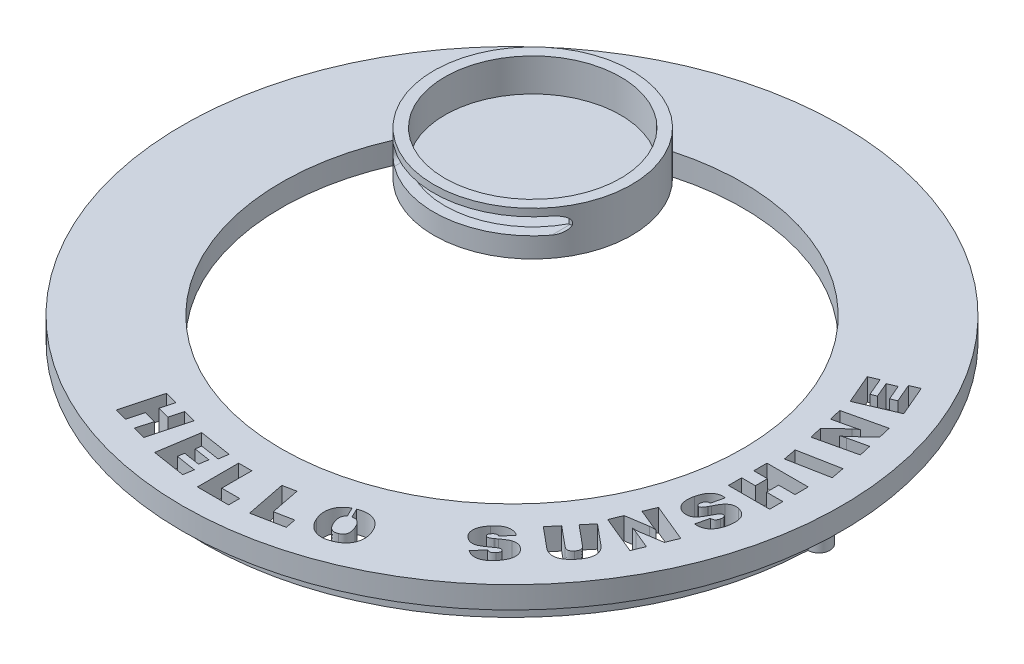
from build123d import *

# Parameters (mm, degrees)
SKETCH1_R            = 30
BOSS_EXTRUDE1_DEPTH  = 2
SKETCH2_R            = 21
CUT_EXTRUDE1_DEPTH   = 2
SKETCH11_R           = 9
BOSS_EXTRUDE3_DEPTH  = 4
SKETCH13_R           = 8
CUT_EXTRUDE10_DEPTH  = 3
CUT_EXTRUDE13_DEPTH  = 10
CUT_EXTRUDE16_DEPTH  = 10
BOSS_EXTRUDE4_DEPTH  = 2
SKETCH20_R           = 28
BOSS_EXTRUDE8_DEPTH  = 2
SKETCH25_R           = 27
CUT_EXTRUDE23_DEPTH  = 2
BOSS_EXTRUDE10_DEPTH = 1
BOSS_EXTRUDE12_DEPTH = 1


with BuildPart() as part:
    # Sketch1 → Boss-Extrude1 (new body)
    with BuildSketch(Plane(origin=(0, 0, 0), x_dir=(1, 0, 0), z_dir=(0, 1, 0))):
        Circle(SKETCH1_R)
    extrude(amount=BOSS_EXTRUDE1_DEPTH)

    # Sketch2 → Cut-Extrude1 (cut)
    with BuildSketch(Plane(origin=(0, 2, 0), x_dir=(1, 0, 0), z_dir=(0, 1, 0))):
        Circle(SKETCH2_R)
    extrude(amount=-CUT_EXTRUDE1_DEPTH, mode=Mode.SUBTRACT)

    # Sketch11 → Boss-Extrude3 (add)
    with BuildSketch(Plane(origin=(0, 0, 0), x_dir=(1, 0, 0), z_dir=(0, 1, 0))):
        with Locations((-11.875702924, 13.763642032)):
            Circle(SKETCH11_R)
    extrude(amount=BOSS_EXTRUDE3_DEPTH)

    # Sketch13 → Cut-Extrude10 (cut)
    with BuildSketch(Plane(origin=(0, 4, 0), x_dir=(1, 0, 0), z_dir=(0, 1, 0))):
        with Locations((-11.875702924, 13.763642032)):
            Circle(SKETCH13_R)
    extrude(amount=-CUT_EXTRUDE10_DEPTH, mode=Mode.SUBTRACT)

    # Sketch16 → Cut-Extrude13 (cut)
    with BuildSketch(Plane.XY):
        with BuildLine():
            Line((-17.291316652, 3.3288405), (-4.708683348, 3.3288405))
            ThreePointArc((-4.708683348, 3.3288405), (-3.958683348, 2.5788405), (-4.708683348, 1.8288405))
            Line((-4.708683348, 1.8288405), (-17.291316652, 1.8288405))
            ThreePointArc((-17.291316652, 1.8288405), (-18.041316652, 2.5788405), (-17.291316652, 3.3288405))
        make_face()
    extrude(amount=-CUT_EXTRUDE13_DEPTH, mode=Mode.SUBTRACT)

    # Sketch18 → Cut-Extrude16 (cut)
    with BuildSketch(Plane(origin=(0, 2, 0), x_dir=(1, 0, 0), z_dir=(0, 1, 0))):
        Polygon((25.568850468, 10.095220619), (22.153206132, 8.631695196), (20.985843532, 11.355040141), (21.803673866, 11.705324089), (22.496724939, 10.088455479), (22.977801606, 10.294416427), (22.392241101, 11.661726517), (23.161963768, 11.991715043), (23.747524274, 10.624404953), (24.276708608, 10.851413005), (23.555093607, 12.53518134), (24.372923941, 12.885465288), align=None)
        with BuildLine():
            Line((26.843323164, 4.870106811), (23.187140494, 4.025967597))
            Line((23.187140494, 4.025967597), (22.931568515, 5.132443931))
            Line((22.931568515, 5.132443931), (24.396597303, 6.544854958))
            add(Edge.make_bspline(
                [(24.396597303, 6.544854958), (24.407714969, 6.556050004), (24.431612554, 6.580113917), (24.473622755, 6.615070259), (24.521946307, 6.653336523), (24.57830382, 6.693091142), (24.64107318, 6.735896512), (24.711215061, 6.780517229), (24.786764614, 6.82913531), (24.840229914, 6.860740529), (24.8679021, 6.877098531)],
                knots=[0, 0, 0, 0, 4.7308e-05, 0.00010169, 0.000163793, 0.000232213, 0.000308519, 0.000391712, 0.00048159, 0.000578017, 0.000578017, 0.000578017, 0.000578017], degree=3))
            add(Edge.make_bspline(
                [(24.8679021, 6.877098531), (24.835146764, 6.865131705), (24.766293518, 6.839976875), (24.676460208, 6.810833605), (24.596901056, 6.788515417), (24.529767515, 6.770398385), (24.456418745, 6.751549036), (24.405143101, 6.739680824), (24.378556928, 6.733527214)],
                knots=[0, 0, 0, 0, 0.000104616, 0.000219908, 0.000283201, 0.000352491, 0.000428515, 0.000510379, 0.000510379, 0.000510379, 0.000510379], degree=3))
            Line((24.378556928, 6.733527214), (22.653446067, 6.335135599))
            Line((22.653446067, 6.335135599), (22.398625769, 7.441611933))
            Line((22.398625769, 7.441611933), (26.05480844, 8.285751147))
            Line((26.05480844, 8.285751147), (26.309628737, 7.179274813))
            Line((26.309628737, 7.179274813), (24.85813023, 5.769870515))
            add(Edge.make_bspline(
                [(24.85813023, 5.769870515), (24.846467171, 5.758720325), (24.821049453, 5.734420319), (24.777677595, 5.698301351), (24.726881479, 5.658805259), (24.646353308, 5.601619029), (24.53214561, 5.52460902), (24.435186151, 5.465293087), (24.383818704, 5.43386853)],
                knots=[0, 0, 0, 0, 4.8395e-05, 0.000105468, 0.000169219, 0.000241396, 0.000401718, 0.000582349, 0.000582349, 0.000582349, 0.000582349], degree=3))
            add(Edge.make_bspline(
                [(24.383818704, 5.43386853), (24.41551991, 5.446706641), (24.480052534, 5.472840566), (24.56510704, 5.50154122), (24.641344107, 5.522748364), (24.70951662, 5.541931906), (24.788854338, 5.561170533), (24.845339279, 5.574238983), (24.875418923, 5.581198259)],
                knots=[0, 0, 0, 0, 0.000102596, 0.000208849, 0.000269045, 0.000339982, 0.000421293, 0.000513917, 0.000513917, 0.000513917, 0.000513917], degree=3))
            Line((24.875418923, 5.581198259), (26.587751185, 5.976583145))
            Line((26.587751185, 5.976583145), (26.843323164, 4.870106811))
        make_face()
        Polygon((27.358585925, 1.795526283), (23.702403255, 1.098716798), (23.473140156, 2.301408465), (27.129322826, 2.99821795), align=None)
        Polygon((26.989940597, -3.536921403), (23.237542594, -3.536921403), (23.237542594, -2.334229735), (24.488341928, -2.334229735), (24.488341928, -1.227753401), (23.237542594, -1.227753401), (23.237542594, -0.025061733), (26.989940597, -0.025061733), (26.989940597, -1.227753401), (25.498602929, -1.227753401), (25.498602929, -2.334229735), (26.989940597, -2.334229735), align=None)
        with BuildLine():
            Line((24.740732099, -8.107504989), (25.009082677, -6.952920988))
            add(Edge.make_bspline(
                [(25.009082677, -6.952920988), (25.042983102, -6.952410304), (25.106995881, -6.951445999), (25.197174908, -6.934922553), (25.275425094, -6.906585767), (25.343033021, -6.864837367), (25.399579396, -6.806686167), (25.44565617, -6.732231968), (25.48431763, -6.641938031), (25.501855246, -6.575122385), (25.511206449, -6.539495727)],
                knots=[0, 0, 0, 0, 0.000101577, 0.000191804, 0.000273624, 0.000349956, 0.000428091, 0.000514626, 0.000611254, 0.000721631, 0.000721631, 0.000721631, 0.000721631], degree=3))
            add(Edge.make_bspline(
                [(25.511206449, -6.539495727), (25.517494981, -6.509038793), (25.529425415, -6.451256722), (25.534502497, -6.366879102), (25.530481015, -6.290419033), (25.513130069, -6.222524542), (25.48552969, -6.164779367), (25.448050324, -6.117088013), (25.397876918, -6.083993633), (25.35998612, -6.072053066), (25.340574568, -6.065935883)],
                knots=[0, 0, 0, 0, 9.3184e-05, 0.000176787, 0.000252889, 0.000321986, 0.000385525, 0.000443755, 0.000501712, 0.000562594, 0.000562594, 0.000562594, 0.000562594], degree=3))
            add(Edge.make_bspline(
                [(25.340574568, -6.065935883), (25.323785901, -6.063706897), (25.289648852, -6.059174614), (25.236199895, -6.071040728), (25.183817738, -6.099226792), (25.129695476, -6.14054443), (25.076327822, -6.198273529), (25.020280224, -6.269318388), (24.964518814, -6.356078614), (24.929257153, -6.420003307), (24.910612297, -6.453803946)],
                knots=[0, 0, 0, 0, 5.0503e-05, 0.000102689, 0.000160846, 0.000227898, 0.000306048, 0.000395973, 0.000499176, 0.000614974, 0.000614974, 0.000614974, 0.000614974], degree=3))
            add(Edge.make_bspline(
                [(24.910612297, -6.453803946), (24.903324859, -6.467322912), (24.889708141, -6.492583358), (24.870871325, -6.528272933), (24.854384665, -6.55873452), (24.844450376, -6.577573563), (24.839954162, -6.586100029)],
                knots=[0, 0, 0, 0, 4.6074e-05, 8.609e-05, 0.000121065, 0.000149983, 0.000149983, 0.000149983, 0.000149983], degree=3))
            add(Edge.make_bspline(
                [(24.839954162, -6.586100029), (24.808570707, -6.646333619), (24.749106485, -6.760462022), (24.66183596, -6.920951818), (24.5818083, -7.061549959), (24.507978454, -7.182720943), (24.439779639, -7.285421313), (24.378751495, -7.372537435), (24.321755401, -7.443206036), (24.283219658, -7.482844422), (24.26566889, -7.500897379)],
                knots=[0, 0, 0, 0, 0.000203754, 0.000386066, 0.000548015, 0.000689051, 0.000811638, 0.000917806, 0.001008086, 0.001083592, 0.001083592, 0.001083592, 0.001083592], degree=3))
            add(Edge.make_bspline(
                [(24.26566889, -7.500897379), (24.232765583, -7.528858882), (24.168511923, -7.583462173), (24.062006481, -7.649042022), (23.952496461, -7.70171763), (23.837565923, -7.737982167), (23.718796326, -7.759210642), (23.595879978, -7.764632649), (23.468865551, -7.75699181), (23.384294171, -7.739729048), (23.341099671, -7.730912161)],
                knots=[0, 0, 0, 0, 0.000129368, 0.00025263, 0.000374015, 0.000493115, 0.000612992, 0.000734913, 0.000861466, 0.000993578, 0.000993578, 0.000993578, 0.000993578], degree=3))
            add(Edge.make_bspline(
                [(23.341099671, -7.730912161), (23.298222352, -7.719525858), (23.214346514, -7.69725218), (23.09555003, -7.649366947), (22.986819677, -7.591006115), (22.888614042, -7.520729214), (22.800003614, -7.440178234), (22.722170119, -7.347356645), (22.654294844, -7.243929838), (22.597282286, -7.129751943), (22.550902009, -7.006855122), (22.516186536, -6.875891204), (22.493999951, -6.737638872), (22.48295308, -6.592082409), (22.483006155, -6.439287539), (22.495505725, -6.279311519), (22.519622615, -6.112117912), (22.543885251, -5.999158011), (22.556343357, -5.941156623)],
                knots=[0, 0, 0, 0, 0.000132988, 0.000260149, 0.000383251, 0.000502352, 0.000621531, 0.000741548, 0.000864762, 0.000991832, 0.001123623, 0.001258183, 0.001397577, 0.001543089, 0.00169568, 0.00185549, 0.002024088, 0.002202021, 0.002202021, 0.002202021, 0.002202021], degree=3))
            add(Edge.make_bspline(
                [(22.556343357, -5.941156623), (22.570403042, -5.884579159), (22.597823574, -5.774236414), (22.649941902, -5.616391088), (22.708790977, -5.469826349), (22.773349099, -5.334229109), (22.847052917, -5.210791184), (22.927112103, -5.098526036), (23.01484014, -4.997949882), (23.108925004, -4.908677202), (23.209886371, -4.831640654), (23.317100118, -4.767437191), (23.429798988, -4.716051116), (23.547924427, -4.677086523), (23.671948709, -4.652956964), (23.801036453, -4.639773192), (23.935796572, -4.640837927), (24.02669567, -4.650720027), (24.073238223, -4.655779903)],
                knots=[0, 0, 0, 0, 0.000174847, 0.000341002, 0.000498174, 0.000648452, 0.00079103, 0.000928918, 0.001061575, 0.001190788, 0.001317374, 0.001441775, 0.001564888, 0.001688258, 0.001814005, 0.001943176, 0.002076977, 0.002217373, 0.002217373, 0.002217373, 0.002217373], degree=3))
            Line((24.073238223, -4.655779903), (23.815411197, -5.762256237))
            add(Edge.make_bspline(
                [(23.815411197, -5.762256237), (23.787579748, -5.761334855), (23.734067969, -5.759563306), (23.65679324, -5.771810065), (23.588276273, -5.799925461), (23.527361412, -5.840073952), (23.476150891, -5.895853455), (23.43233752, -5.964411052), (23.397120302, -6.047661498), (23.381127948, -6.10878088), (23.372670327, -6.141104112)],
                knots=[0, 0, 0, 0, 8.3437e-05, 0.000160425, 0.00023259, 0.000304099, 0.000377479, 0.000457962, 0.000547187, 0.000647342, 0.000647342, 0.000647342, 0.000647342], degree=3))
            add(Edge.make_bspline(
                [(23.372670327, -6.141104112), (23.366845415, -6.169817979), (23.355922494, -6.223662443), (23.34893385, -6.300679038), (23.353880658, -6.368285969), (23.368884615, -6.4266291), (23.396382879, -6.475309261), (23.434148654, -6.51505609), (23.483912079, -6.543906161), (23.52145242, -6.554837208), (23.54104716, -6.560542831)],
                knots=[0, 0, 0, 0, 8.7873e-05, 0.00016478, 0.000231137, 0.000290406, 0.000343923, 0.000397086, 0.000453034, 0.000514124, 0.000514124, 0.000514124, 0.000514124], degree=3))
            add(Edge.make_bspline(
                [(23.54104716, -6.560542831), (23.556618, -6.562570616), (23.588722263, -6.566751542), (23.638721688, -6.55269209), (23.688481463, -6.523960463), (23.739668944, -6.480891704), (23.791832368, -6.422937387), (23.846187953, -6.350795668), (23.901452992, -6.263296738), (23.936574122, -6.198705453), (23.955224104, -6.164406263)],
                knots=[0, 0, 0, 0, 4.6701e-05, 9.6289e-05, 0.000152142, 0.000218358, 0.000296026, 0.000385627, 0.000489054, 0.000606162, 0.000606162, 0.000606162, 0.000606162], degree=3))
            add(Edge.make_bspline(
                [(23.955224104, -6.164406263), (23.961543262, -6.153412289), (23.972556232, -6.134252097), (23.983066771, -6.11481217), (23.987546442, -6.106526727)],
                knots=[0, 0, 0, 0, 3.804e-05, 6.6296e-05, 6.6296e-05, 6.6296e-05, 6.6296e-05], degree=3))
            add(Edge.make_bspline(
                [(23.987546442, -6.106526727), (23.993814682, -6.094251395), (24.007625118, -6.067205897), (24.030404663, -6.022344631), (24.057393565, -5.969315703), (24.076527291, -5.930899627), (24.086768505, -5.910337649)],
                knots=[0, 0, 0, 0, 4.1349e-05, 9.1103e-05, 0.00015094, 0.000219854, 0.000219854, 0.000219854, 0.000219854], degree=3))
            add(Edge.make_bspline(
                [(24.086768505, -5.910337649), (24.111398285, -5.863137917), (24.1584904, -5.772892079), (24.228747305, -5.645030018), (24.293528956, -5.529586022), (24.355759057, -5.42848329), (24.413808126, -5.340807508), (24.46716334, -5.266151829), (24.515662123, -5.203750367), (24.549989315, -5.169645178), (24.565590125, -5.154145262)],
                knots=[0, 0, 0, 0, 0.000159713, 0.00030537, 0.000437671, 0.000556793, 0.000661449, 0.000753025, 0.000832149, 0.000898066, 0.000898066, 0.000898066, 0.000898066], degree=3))
            add(Edge.make_bspline(
                [(24.565590125, -5.154145262), (24.600685988, -5.12217038), (24.668594853, -5.060300467), (24.779443481, -4.985048255), (24.89106026, -4.925929059), (25.005829493, -4.885297993), (25.124580198, -4.861994213), (25.248341157, -4.853699491), (25.37821225, -4.862127413), (25.46501391, -4.879735846), (25.509703084, -4.888801413)],
                knots=[0, 0, 0, 0, 0.000142275, 0.000275295, 0.0004007, 0.000520283, 0.000639101, 0.000762654, 0.000891458, 0.001028142, 0.001028142, 0.001028142, 0.001028142], degree=3))
            add(Edge.make_bspline(
                [(25.509703084, -4.888801413), (25.557618258, -4.901075173), (25.65091304, -4.924973191), (25.782627028, -4.976815779), (25.902660256, -5.039149537), (26.011732938, -5.112421892), (26.107855133, -5.198132336), (26.194290941, -5.293351939), (26.267086829, -5.400985237), (26.328124431, -5.518890628), (26.376991153, -5.646781174), (26.413690715, -5.783804583), (26.437595936, -5.929832709), (26.448613535, -6.084786949), (26.446533067, -6.248612703), (26.432777151, -6.421368431), (26.406497857, -6.602938568), (26.379675083, -6.725810971), (26.365869215, -6.789054248)],
                knots=[0, 0, 0, 0, 0.000148272, 0.000288698, 0.00042352, 0.000553406, 0.00068175, 0.000808971, 0.000938237, 0.001070364, 0.00120647, 0.001348148, 0.001495203, 0.00164971, 0.001813584, 0.00198625, 0.002169306, 0.002363457, 0.002363457, 0.002363457, 0.002363457], degree=3))
            add(Edge.make_bspline(
                [(26.365869215, -6.789054248), (26.351396678, -6.847165175), (26.323189582, -6.96042385), (26.268345281, -7.122396448), (26.207110662, -7.273413858), (26.137302629, -7.412863965), (26.059079134, -7.540571623), (25.972191799, -7.65630568), (25.877385001, -7.760361139), (25.775031224, -7.852494852), (25.665551612, -7.931624633), (25.550502584, -7.998418126), (25.428896985, -8.050305856), (25.302125108, -8.090094316), (25.169047207, -8.114250941), (25.030918642, -8.126358344), (24.887102216, -8.125087919), (24.790268644, -8.113455641), (24.740732099, -8.107504989)],
                knots=[0, 0, 0, 0, 0.000179591, 0.000350024, 0.000512505, 0.000668149, 0.00081731, 0.000961182, 0.001101648, 0.001238982, 0.001373552, 0.001506226, 0.001637202, 0.001769395, 0.001903997, 0.00204208, 0.002184907, 0.002334498, 0.002334498, 0.002334498, 0.002334498], degree=3))
        make_face()
        with BuildLine():
            Line((23.893372821, -13.155473877), (20.429620818, -11.720512381))
            Line((20.429620818, -11.720512381), (20.867851595, -10.662143713))
            Line((20.867851595, -10.662143713), (22.884615185, -10.350195562))
            add(Edge.make_bspline(
                [(22.884615185, -10.350195562), (22.900372968, -10.347489774), (22.934000838, -10.341715493), (22.988512616, -10.336843184), (23.050197814, -10.333929447), (23.119400547, -10.333258522), (23.195574441, -10.335138299), (23.278823382, -10.337689872), (23.368483741, -10.344242769), (23.430590808, -10.349159992), (23.462658868, -10.351698927)],
                knots=[0, 0, 0, 0, 4.7949e-05, 0.000102325, 0.000164036, 0.000233195, 0.000309882, 0.000392621, 0.000483023, 0.000579532, 0.000579532, 0.000579532, 0.000579532], degree=3))
            add(Edge.make_bspline(
                [(23.462658868, -10.351698927), (23.428781706, -10.342359747), (23.35792849, -10.322827093), (23.267697526, -10.294640076), (23.189790235, -10.266958531), (23.124754057, -10.242086567), (23.054075146, -10.214314288), (23.005361609, -10.194406237), (22.980078836, -10.184073776)],
                knots=[0, 0, 0, 0, 0.000105421, 0.000220484, 0.000283487, 0.00035343, 0.000429365, 0.000511301, 0.000511301, 0.000511301, 0.000511301], degree=3))
            Line((22.980078836, -10.184073776), (21.345921532, -9.507559712))
            Line((21.345921532, -9.507559712), (21.784903991, -8.449191045))
            Line((21.784903991, -8.449191045), (25.248655994, -9.884152541))
            Line((25.248655994, -9.884152541), (24.809673536, -10.942521209))
            Line((24.809673536, -10.942521209), (22.805688544, -11.259731136))
            add(Edge.make_bspline(
                [(22.805688544, -11.259731136), (22.789420057, -11.26212828), (22.75447682, -11.267277129), (22.698038418, -11.272380444), (22.633837012, -11.275256356), (22.534807482, -11.276039441), (22.397120348, -11.271785227), (22.283746324, -11.26389635), (22.22388645, -11.259731136)],
                knots=[0, 0, 0, 0, 4.9325e-05, 0.000105947, 0.00016991, 0.000242076, 0.000402999, 0.000583005, 0.000583005, 0.000583005, 0.000583005], degree=3))
            add(Edge.make_bspline(
                [(22.22388645, -11.259731136), (22.257071526, -11.267588536), (22.324739198, -11.283610555), (22.409985424, -11.310811788), (22.484357864, -11.336754234), (22.550804508, -11.360561726), (22.626347419, -11.39113137), (22.680155976, -11.412830212), (22.708721529, -11.424349558)],
                knots=[0, 0, 0, 0, 0.000102276, 0.00020855, 0.000268218, 0.000338604, 0.000420261, 0.000512666, 0.000512666, 0.000512666, 0.000512666], degree=3))
            Line((22.708721529, -11.424349558), (24.331603598, -12.09710521))
            Line((24.331603598, -12.09710521), (23.893372821, -13.155473877))
        make_face()
        with BuildLine():
            Line((18.06738426, -15.216797358), (18.825831693, -14.30275169))
            Line((18.825831693, -14.30275169), (20.587023304, -15.764022067))
            add(Edge.make_bspline(
                [(20.587023304, -15.764022067), (20.606861887, -15.780079938), (20.645183087, -15.811098127), (20.70388021, -15.851501655), (20.760383975, -15.885871435), (20.815434693, -15.913086925), (20.868640594, -15.933856133), (20.920510951, -15.946593101), (20.970118615, -15.953705785), (21.018574832, -15.954150893), (21.065932242, -15.945757836), (21.113696335, -15.93261363), (21.161536451, -15.910879933), (21.209243623, -15.882059844), (21.257708398, -15.847342151), (21.306041473, -15.80539649), (21.354800929, -15.756680831), (21.385808311, -15.720399164), (21.401846909, -15.701632436)],
                knots=[0, 0, 0, 0, 7.6543e-05, 0.000147853, 0.000213599, 0.000274781, 0.000331879, 0.000384567, 0.000434637, 0.000481993, 0.0005292, 0.000578451, 0.000630273, 0.000686222, 0.000745466, 0.000808898, 0.000877996, 0.000952031, 0.000952031, 0.000952031, 0.000952031], degree=3))
            add(Edge.make_bspline(
                [(21.401846909, -15.701632436), (21.416859449, -15.682762164), (21.44589509, -15.646265312), (21.484085881, -15.590797774), (21.516384486, -15.537120161), (21.541252283, -15.484465902), (21.55959987, -15.433138869), (21.571214317, -15.383187445), (21.575637284, -15.334657057), (21.574434889, -15.287352072), (21.565829153, -15.240221982), (21.549806455, -15.193068488), (21.526703004, -15.144973734), (21.496588845, -15.096463934), (21.459310841, -15.047188309), (21.414621246, -14.997879227), (21.363433851, -14.947122809), (21.325409796, -14.914863666), (21.305631576, -14.898084066)],
                knots=[0, 0, 0, 0, 7.2322e-05, 0.000139877, 0.000201885, 0.000260057, 0.000314261, 0.000365138, 0.000413456, 0.000460085, 0.000506677, 0.000556595, 0.000609046, 0.000666415, 0.000727602, 0.000794146, 0.000865904, 0.000943687, 0.000943687, 0.000943687, 0.000943687], degree=3))
            Line((21.305631576, -14.898084066), (19.544439965, -13.436813689))
            Line((19.544439965, -13.436813689), (20.30363908, -12.522768022))
            Line((20.30363908, -12.522768022), (22.136240509, -14.043421299))
            add(Edge.make_bspline(
                [(22.136240509, -14.043421299), (22.178815265, -14.08048283), (22.261803437, -14.152724432), (22.370956527, -14.271234626), (22.463509169, -14.393526431), (22.539538988, -14.51985077), (22.598870478, -14.650617816), (22.640495665, -14.786023479), (22.664583684, -14.92571334), (22.671880443, -15.069004195), (22.662916203, -15.215575225), (22.635769681, -15.364605523), (22.592753245, -15.515908658), (22.532485894, -15.669479873), (22.455657947, -15.825198828), (22.360434967, -15.98244684), (22.250187748, -16.142976578), (22.16651258, -16.247134319), (22.12346191, -16.300723223)],
                knots=[0, 0, 0, 0, 0.000169237, 0.000329883, 0.000482324, 0.00062864, 0.000771287, 0.000912047, 0.001052432, 0.00119545, 0.001341555, 0.001491955, 0.001649001, 0.00181274, 0.001986203, 0.002169259, 0.002363795, 0.002569949, 0.002569949, 0.002569949, 0.002569949], degree=3))
            add(Edge.make_bspline(
                [(22.12346191, -16.300723223), (22.078484445, -16.353154013), (21.991044576, -16.455083754), (21.853278942, -16.594314318), (21.714938388, -16.716765373), (21.575649347, -16.821940888), (21.435122123, -16.909903686), (21.293800232, -16.981028594), (21.151228914, -17.034989243), (21.008425105, -17.072478108), (20.865241364, -17.091008485), (20.722913743, -17.093885085), (20.581710483, -17.077844671), (20.442002458, -17.043782694), (20.303094196, -16.99454401), (20.166424435, -16.925365741), (20.030247528, -16.84037588), (19.944211209, -16.772395041), (19.899985689, -16.737450635)],
                knots=[0, 0, 0, 0, 0.000207188, 0.00040279, 0.000587067, 0.000761006, 0.000925781, 0.001083777, 0.001234835, 0.001382328, 0.001525634, 0.001666968, 0.001808416, 0.001950625, 0.002097563, 0.002249509, 0.002409264, 0.002578245, 0.002578245, 0.002578245, 0.002578245], degree=3))
            Line((19.899985689, -16.737450635), (18.06738426, -15.216797358))
        make_face()
        with BuildLine():
            Line((16.584587875, -20.487263593), (17.34378699, -19.573217926))
            add(Edge.make_bspline(
                [(17.34378699, -19.573217926), (17.372991461, -19.586925876), (17.428537576, -19.612998026), (17.513642792, -19.635874936), (17.593959934, -19.64383532), (17.670930519, -19.633813611), (17.744914187, -19.605199335), (17.818293439, -19.559118995), (17.892093185, -19.495135835), (17.937519596, -19.443053435), (17.961669835, -19.415364644)],
                knots=[0, 0, 0, 0, 9.6628e-05, 0.000183785, 0.000263001, 0.000337311, 0.000414379, 0.00049908, 0.000596102, 0.000706231, 0.000706231, 0.000706231, 0.000706231], degree=3))
            add(Edge.make_bspline(
                [(17.961669835, -19.415364644), (17.981036392, -19.390978892), (18.017811873, -19.344672379), (18.061270665, -19.272365049), (18.090498608, -19.202156435), (18.107325295, -19.135172939), (18.109117827, -19.071771149), (18.097631483, -19.013405148), (18.069468564, -18.961726528), (18.041403474, -18.935107781), (18.027066194, -18.921509378)],
                knots=[0, 0, 0, 0, 9.336e-05, 0.000177283, 0.000252105, 0.000320841, 0.000383249, 0.000440894, 0.000497405, 0.000556425, 0.000556425, 0.000556425, 0.000556425], degree=3))
            add(Edge.make_bspline(
                [(18.027066194, -18.921509378), (18.013450173, -18.912397861), (17.985760149, -18.893868356), (17.934031502, -18.881157764), (17.875863172, -18.883387005), (17.810265371, -18.896517832), (17.738139443, -18.924273387), (17.65782279, -18.963008026), (17.57047077, -19.015147359), (17.511161201, -19.056187271), (17.479841485, -19.077859295)],
                knots=[0, 0, 0, 0, 4.8859e-05, 9.9362e-05, 0.000156495, 0.00022239, 0.000299198, 0.000387619, 0.000489721, 0.000603969, 0.000603969, 0.000603969, 0.000603969], degree=3))
            add(Edge.make_bspline(
                [(17.479841485, -19.077859295), (17.46758014, -19.086901614), (17.444347465, -19.104034909), (17.411635274, -19.127646804), (17.383774872, -19.148222908), (17.366606792, -19.160319854), (17.358820636, -19.165806123)],
                knots=[0, 0, 0, 0, 4.5705e-05, 8.66e-05, 0.00012103, 0.000149604, 0.000149604, 0.000149604, 0.000149604], degree=3))
            add(Edge.make_bspline(
                [(17.358820636, -19.165806123), (17.303787827, -19.205270379), (17.199445581, -19.280094637), (17.050063692, -19.384293003), (16.915456305, -19.472860083), (16.79624893, -19.548104516), (16.690342038, -19.609883569), (16.596131676, -19.658651245), (16.514236302, -19.697652734), (16.461735244, -19.714974799), (16.438009828, -19.722802702)],
                knots=[0, 0, 0, 0, 0.000203162, 0.000385194, 0.000546351, 0.000686505, 0.000808085, 0.000913989, 0.001004815, 0.001079701, 0.001079701, 0.001079701, 0.001079701], degree=3))
            add(Edge.make_bspline(
                [(16.438009828, -19.722802702), (16.396087457, -19.732505878), (16.313910861, -19.751526127), (16.189454849, -19.76373992), (16.067706788, -19.75997832), (15.948773418, -19.740984878), (15.832737155, -19.707320718), (15.720814224, -19.655979572), (15.609974855, -19.592956776), (15.542098424, -19.53909339), (15.50742715, -19.511579978)],
                knots=[0, 0, 0, 0, 0.000128994, 0.000252855, 0.000373934, 0.000493435, 0.000613314, 0.000735124, 0.000862113, 0.00099471, 0.00099471, 0.00099471, 0.00099471], degree=3))
            add(Edge.make_bspline(
                [(15.50742715, -19.511579978), (15.473988801, -19.482156351), (15.408694261, -19.424701296), (15.322943552, -19.329299697), (15.251703662, -19.228126991), (15.195086985, -19.121380753), (15.151604847, -19.009704696), (15.122194278, -18.892806356), (15.107436526, -18.770373785), (15.105906008, -18.643572394), (15.11911288, -18.513369388), (15.145613362, -18.381489154), (15.185760256, -18.248300832), (15.240552888, -18.114679112), (15.307714598, -17.979270334), (15.389548992, -17.843114439), (15.484933234, -17.70565885), (15.556487487, -17.616420784), (15.593118932, -17.570736299)],
                knots=[0, 0, 0, 0, 0.000133539, 0.00026076, 0.000383798, 0.000503846, 0.000622359, 0.000742502, 0.000864453, 0.000991496, 0.001122163, 0.001256313, 0.001394477, 0.001538808, 0.001689073, 0.001847507, 0.002014945, 0.002190575, 0.002190575, 0.002190575, 0.002190575], degree=3))
            add(Edge.make_bspline(
                [(15.593118932, -17.570736299), (15.630684475, -17.526917619), (15.703777257, -17.44165786), (15.819242478, -17.324866324), (15.935741273, -17.220926491), (16.054828922, -17.131992388), (16.173631025, -17.053754377), (16.295468568, -16.991539277), (16.418038887, -16.941371525), (16.541963153, -16.905070896), (16.666137683, -16.882142655), (16.790224979, -16.873949689), (16.913474013, -16.879237686), (17.036093386, -16.897992475), (17.157675392, -16.931645601), (17.278744722, -16.978778534), (17.399267521, -17.039476841), (17.47603818, -17.089644716), (17.515170553, -17.11521683)],
                knots=[0, 0, 0, 0, 0.000173104, 0.000336816, 0.000492314, 0.000640997, 0.000782361, 0.000918517, 0.001050705, 0.001179152, 0.001305213, 0.001428766, 0.001551403, 0.001674617, 0.001800076, 0.001929059, 0.002063862, 0.002204016, 0.002204016, 0.002204016, 0.002204016], degree=3))
            Line((17.515170553, -17.11521683), (16.795810599, -17.98115483))
            add(Edge.make_bspline(
                [(16.795810599, -17.98115483), (16.773412357, -17.969179186), (16.730374005, -17.946167916), (16.661317997, -17.928027509), (16.593278517, -17.923845179), (16.525708843, -17.934614118), (16.459017085, -17.961423168), (16.392867094, -18.003103695), (16.327261922, -18.060567398), (16.286646467, -18.106433524), (16.265122901, -18.130739607)],
                knots=[0, 0, 0, 0, 7.5979e-05, 0.000145995, 0.00021225, 0.00027923, 0.000349442, 0.000426412, 0.000512754, 0.000610093, 0.000610093, 0.000610093, 0.000610093], degree=3))
            add(Edge.make_bspline(
                [(16.265122901, -18.130739607), (16.247579168, -18.152927564), (16.214618481, -18.194613692), (16.17585908, -18.258529987), (16.149657649, -18.318602064), (16.137754867, -18.37542531), (16.138463276, -18.429098591), (16.154643332, -18.478889164), (16.183069645, -18.525551659), (16.210758551, -18.550579417), (16.225283739, -18.563708607)],
                knots=[0, 0, 0, 0, 8.479e-05, 0.000159302, 0.000223657, 0.000280413, 0.000332301, 0.000382703, 0.00043569, 0.000494157, 0.000494157, 0.000494157, 0.000494157], degree=3))
            add(Edge.make_bspline(
                [(16.225283739, -18.563708607), (16.237639693, -18.572175094), (16.263019966, -18.589566043), (16.311717763, -18.598076179), (16.366440683, -18.595289216), (16.428600518, -18.578794522), (16.498335084, -18.551446279), (16.5755378, -18.511363803), (16.660340587, -18.459138037), (16.718357627, -18.418462846), (16.749206297, -18.396835138)],
                knots=[0, 0, 0, 0, 4.4476e-05, 9.1359e-05, 0.000144776, 0.000208221, 0.000283182, 0.000369242, 0.000468766, 0.000581771, 0.000581771, 0.000581771, 0.000581771], degree=3))
            add(Edge.make_bspline(
                [(16.749206297, -18.396835138), (16.759503065, -18.389602097), (16.777141123, -18.377212113), (16.794569882, -18.364529687), (16.801824058, -18.359251024)],
                knots=[0, 0, 0, 0, 3.7749e-05, 6.4663e-05, 6.4663e-05, 6.4663e-05, 6.4663e-05], degree=3))
            add(Edge.make_bspline(
                [(16.801824058, -18.359251024), (16.812897978, -18.351299291), (16.837772333, -18.333438025), (16.877579051, -18.302318017), (16.926509635, -18.26734059), (16.960762357, -18.241097362), (16.979221079, -18.22695494)],
                knots=[0, 0, 0, 0, 4.0896e-05, 9.1861e-05, 0.000151547, 0.000221304, 0.000221304, 0.000221304, 0.000221304], degree=3))
            add(Edge.make_bspline(
                [(16.979221079, -18.22695494), (17.022194003, -18.195462078), (17.104639512, -18.13504159), (17.224575802, -18.05130652), (17.334375864, -17.976886707), (17.435222272, -17.914001832), (17.525804981, -17.860077381), (17.60724709, -17.817331272), (17.678242027, -17.78305818), (17.723742562, -17.767317991), (17.744433652, -17.760160237)],
                knots=[0, 0, 0, 0, 0.000159826, 0.000306633, 0.000438809, 0.000557689, 0.000663145, 0.000754939, 0.000833637, 0.00089927, 0.00089927, 0.00089927, 0.00089927], degree=3))
            add(Edge.make_bspline(
                [(17.744433652, -17.760160237), (17.790056932, -17.747416146), (17.878401433, -17.722738605), (18.010587153, -17.7026883), (18.136415995, -17.70032372), (18.256664075, -17.713589835), (18.372679923, -17.744529019), (18.486192901, -17.791629989), (18.597794924, -17.855945147), (18.666647391, -17.910326076), (18.702076893, -17.93830894)],
                knots=[0, 0, 0, 0, 0.000142022, 0.000275011, 0.00039981, 0.000518597, 0.000636743, 0.000758747, 0.000886387, 0.00102169, 0.00102169, 0.00102169, 0.00102169], degree=3))
            add(Edge.make_bspline(
                [(18.702076893, -17.93830894), (18.738881106, -17.970380218), (18.81076055, -18.033016136), (18.903842388, -18.137282426), (18.982561323, -18.245530421), (19.045448483, -18.359118385), (19.093316516, -18.47768326), (19.124921346, -18.601335799), (19.141390471, -18.729289274), (19.142994235, -18.861525331), (19.127782393, -18.99720049), (19.099629002, -19.135930872), (19.05408185, -19.276513489), (18.994502387, -19.419933265), (18.918618394, -19.565408695), (18.828917553, -19.714064685), (18.72339863, -19.864530469), (18.64428975, -19.96254582), (18.603606512, -20.012952067)],
                knots=[0, 0, 0, 0, 0.000146331, 0.000285788, 0.000418259, 0.000547122, 0.000674283, 0.000800809, 0.000928915, 0.001060468, 0.001196522, 0.001337751, 0.001484429, 0.001639102, 0.001803162, 0.001976163, 0.002159672, 0.002353963, 0.002353963, 0.002353963, 0.002353963], degree=3))
            add(Edge.make_bspline(
                [(18.603606512, -20.012952067), (18.564586463, -20.058566109), (18.48858698, -20.147408733), (18.367899274, -20.268876737), (18.245143756, -20.375942175), (18.120899152, -20.469562845), (17.99516907, -20.550132791), (17.866834646, -20.615550104), (17.737019807, -20.668248734), (17.605422295, -20.705716736), (17.473687586, -20.729265404), (17.342654249, -20.738385135), (17.212713603, -20.733506185), (17.084113729, -20.712343686), (16.956300447, -20.678919063), (16.830269389, -20.628942781), (16.704802324, -20.566121735), (16.62519184, -20.513898937), (16.584587875, -20.487263593)],
                knots=[0, 0, 0, 0, 0.000180034, 0.000350652, 0.00051315, 0.000668297, 0.00081698, 0.000960528, 0.001099833, 0.001236641, 0.001370233, 0.001500587, 0.001629983, 0.001759371, 0.001890831, 0.002025536, 0.002165381, 0.002310953, 0.002310953, 0.002310953, 0.002310953], degree=3))
        make_face()
        with BuildLine():
            add(Edge.make_bspline(
                [(7.110408336, -24.886331589), (7.083431281, -24.81783717), (7.030749771, -24.684079444), (6.973151574, -24.481193611), (6.933978838, -24.283364462), (6.914869249, -24.090259914), (6.915334971, -23.901820119), (6.935669517, -23.718083063), (6.975556882, -23.539035482), (7.035335002, -23.366087219), (7.112336342, -23.200276566), (7.208684893, -23.044931427), (7.321328276, -22.899606604), (7.451282401, -22.765135292), (7.599265406, -22.642647951), (7.762993096, -22.529113187), (7.944966039, -22.42769242), (8.074587566, -22.369951767), (8.140964759, -22.340383665)],
                knots=[0, 0, 0, 0, 0.000220736, 0.00043106, 0.000631697, 0.000825043, 0.001012213, 0.001195996, 0.001378545, 0.001561346, 0.001743943, 0.001925852, 0.002108535, 0.002294594, 0.002485637, 0.002683929, 0.00289157, 0.003109497, 0.003109497, 0.003109497, 0.003109497], degree=3))
            add(Edge.make_bspline(
                [(8.140964759, -22.340383665), (8.208464024, -22.313936621), (8.340241627, -22.262304533), (8.54024996, -22.205707636), (8.735809754, -22.169538041), (8.926583902, -22.151198585), (9.11301135, -22.154720836), (9.294910034, -22.175779433), (9.472271145, -22.218707277), (9.644068757, -22.28030183), (9.808890398, -22.35976847), (9.96394007, -22.45766397), (10.108975244, -22.57217066), (10.242597293, -22.705143223), (10.366186558, -22.854843896), (10.47986898, -23.021502951), (10.582535205, -23.205912884), (10.640601686, -23.337363557), (10.670375673, -23.404765791)],
                knots=[0, 0, 0, 0, 0.000217393, 0.000424413, 0.000622414, 0.000813374, 0.000998312, 0.001180775, 0.001361635, 0.001544473, 0.001727361, 0.001909426, 0.002093501, 0.002280599, 0.002473856, 0.002675051, 0.002885028, 0.003105999, 0.003105999, 0.003105999, 0.003105999], degree=3))
            add(Edge.make_bspline(
                [(10.670375673, -23.404765791), (10.697433669, -23.47298485), (10.75024148, -23.606124758), (10.806761087, -23.808756623), (10.846104157, -24.006217508), (10.865131763, -24.199333165), (10.864771309, -24.387788446), (10.844108948, -24.571400927), (10.805462381, -24.750661581), (10.745421439, -24.923516677), (10.668360817, -25.08910738), (10.572918572, -25.244664395), (10.460951455, -25.389939201), (10.331730509, -25.524670818), (10.183774817, -25.646975632), (10.020279833, -25.759993502), (9.839476329, -25.862427485), (9.710025408, -25.919277366), (9.643577661, -25.948458668)],
                knots=[0, 0, 0, 0, 0.000220032, 0.000429427, 0.000630064, 0.00082341, 0.001010581, 0.001194363, 0.00137675, 0.001559551, 0.001742148, 0.001923663, 0.002105887, 0.002291424, 0.002482467, 0.002680759, 0.00288709, 0.003104702, 0.003104702, 0.003104702, 0.003104702], degree=3))
            add(Edge.make_bspline(
                [(9.643577661, -25.948458668), (9.575801466, -25.974833772), (9.443627699, -26.026269187), (9.243349239, -26.083864827), (9.04758521, -26.121286586), (8.855914232, -26.137825121), (8.66901653, -26.136055174), (8.486165084, -26.114293392), (8.308224255, -26.071877345), (8.135760642, -26.010189983), (7.971341112, -25.929669833), (7.816067759, -25.831985259), (7.671047594, -25.717418633), (7.537500031, -25.584412091), (7.413672094, -25.435027375), (7.301418079, -25.267736207), (7.197151796, -25.084895267), (7.139780651, -24.953567493), (7.110408336, -24.886331589)],
                knots=[0, 0, 0, 0, 0.000218098, 0.000425324, 0.000624202, 0.000815095, 0.001001526, 0.001183988, 0.001366311, 0.001549149, 0.001732365, 0.001914431, 0.002098506, 0.002285603, 0.00247886, 0.002679633, 0.002889321, 0.003109296, 0.003109296, 0.003109296, 0.003109296], degree=3))
        make_face()
        with BuildLine():
            add(Edge.make_bspline(
                [(8.21688467, -24.427805391), (8.233471399, -24.466600018), (8.265524555, -24.541569004), (8.319344967, -24.646911256), (8.374008591, -24.742678786), (8.430173478, -24.828523376), (8.487914911, -24.904426206), (8.548376233, -24.969323275), (8.610193195, -25.024893907), (8.674203287, -25.07066295), (8.741421202, -25.105579516), (8.810780719, -25.131450456), (8.883133396, -25.147490063), (8.958206755, -25.153109559), (9.036210931, -25.150241869), (9.116949675, -25.136707331), (9.200777628, -25.115322903), (9.2559152, -25.093661532), (9.284273526, -25.082520667)],
                knots=[0, 0, 0, 0, 0.000126542, 0.000244537, 0.000354647, 0.000457221, 0.000552091, 0.000640381, 0.000722905, 0.000801113, 0.000875753, 0.000949479, 0.001022613, 0.001097272, 0.001174753, 0.001256192, 0.00134243, 0.001433752, 0.001433752, 0.001433752, 0.001433752], degree=3))
            add(Edge.make_bspline(
                [(9.284273526, -25.082520667), (9.311828376, -25.070238007), (9.365342112, -25.046384093), (9.439553742, -25.00330184), (9.504895733, -24.955489585), (9.561689607, -24.902967841), (9.609216772, -24.845447435), (9.648809065, -24.783532368), (9.679128512, -24.716706536), (9.700298177, -24.644834029), (9.712793421, -24.567836737), (9.717333594, -24.484929585), (9.712267526, -24.396359429), (9.699111705, -24.301682891), (9.678002046, -24.201223278), (9.648018857, -24.094745349), (9.61092667, -23.982047847), (9.579912999, -23.906209121), (9.563899338, -23.867050401)],
                knots=[0, 0, 0, 0, 9.0458e-05, 0.000175677, 0.000256863, 0.000332916, 0.00040712, 0.000480107, 0.000552768, 0.000626494, 0.000704223, 0.00078628, 0.000875093, 0.000969919, 0.00107282, 0.001182786, 0.001301638, 0.001428521, 0.001428521, 0.001428521, 0.001428521], degree=3))
            add(Edge.make_bspline(
                [(9.563899338, -23.867050401), (9.546919432, -23.827825342), (9.514180244, -23.752194978), (9.461786269, -23.6449021), (9.406865848, -23.548621581), (9.350543707, -23.46217119), (9.291995356, -23.386479425), (9.232673294, -23.320060714), (9.170849769, -23.264893078), (9.107136891, -23.219784323), (9.040921166, -23.184671218), (8.972152991, -23.159150075), (8.900785641, -23.141857659), (8.826309159, -23.136495491), (8.7491614, -23.139582689), (8.669006096, -23.151869226), (8.586023213, -23.173607525), (8.53138626, -23.195208166), (8.503275624, -23.206321666)],
                knots=[0, 0, 0, 0, 0.000128221, 0.000247224, 0.000357987, 0.000460561, 0.000556485, 0.00064482, 0.000727344, 0.000804504, 0.000878479, 0.0009515, 0.001024068, 0.001097978, 0.001174708, 0.001255289, 0.0013408, 0.001431417, 0.001431417, 0.001431417, 0.001431417], degree=3))
            add(Edge.make_bspline(
                [(8.503275624, -23.206321666), (8.475442082, -23.218549445), (8.421269164, -23.24234859), (8.34680628, -23.286164648), (8.280777197, -23.334497934), (8.223199502, -23.387142726), (8.174252091, -23.444735139), (8.135145598, -23.507810819), (8.103900891, -23.575083024), (8.081923808, -23.647428214), (8.06944092, -23.725020658), (8.065137699, -23.808156817), (8.069265485, -23.897196997), (8.081387463, -23.992249255), (8.102856912, -24.092867729), (8.132727781, -24.199368564), (8.170003965, -24.312250305), (8.200892975, -24.388387857), (8.21688467, -24.427805391)],
                knots=[0, 0, 0, 0, 9.114e-05, 0.000177387, 0.000258572, 0.000336239, 0.000410925, 0.000484548, 0.000558205, 0.000632868, 0.000710597, 0.000793405, 0.000882183, 0.000977656, 0.001080556, 0.001190523, 0.001309375, 0.001436957, 0.001436957, 0.001436957, 0.001436957], degree=3))
        make_face(mode=Mode.SUBTRACT)
        Polygon((3.628999823, -27.516232), (2.905129775, -23.86004933), (4.059713776, -23.631537913), (4.593408204, -26.325567249), (6.229068872, -26.002343863), (6.419244492, -26.964497197), align=None)
        Polygon((-0.811687654, -27.824439963), (-0.811687654, -24.07204196), (0.391004013, -24.07204196), (0.391004013, -26.814178962), (2.026664681, -26.814178962), (2.026664681, -27.824439963), align=None)
        Polygon((-5.478405955, -27.052362958), (-4.898107225, -23.348072621), (-1.939485722, -23.811860596), (-2.074788535, -24.677798596), (-3.83071837, -24.402682877), (-3.914155104, -24.931867211), (-2.429582577, -25.16413704), (-2.557368566, -25.981967374), (-4.041941094, -25.749697545), (-4.132142969, -26.326989546), (-2.304051634, -26.613380499), (-2.447622952, -27.527426167), align=None)
        Polygon((-10.575257048, -25.454037625), (-9.595063338, -21.845962622), (-8.440479337, -22.159414138), (-8.766709452, -23.362105806), (-7.660233118, -23.662778723), (-7.334003003, -22.460087055), (-6.179419002, -22.774290253), (-7.159612711, -26.382365256), (-8.314196712, -26.068162058), (-7.921818556, -24.624932057), (-9.02829489, -24.32425914), (-9.420673047, -25.767489141), align=None)
    extrude(amount=-CUT_EXTRUDE16_DEPTH, mode=Mode.SUBTRACT)

    # Sketch19 → Boss-Extrude4 (add)
    with BuildSketch(Plane(origin=(0, 2, 0), x_dir=(1, 0, 0), z_dir=(0, 1, 0))):
        Polygon((8.314125905, -23.310521784), (8.5989248, -23.171357203), (8.178470415, -22.310901596), (7.89367152, -22.450066177), align=None)
    extrude(amount=-BOSS_EXTRUDE4_DEPTH)

    # Sketch20 → Boss-Extrude8 (add)
    with BuildSketch(Plane(origin=(0, 0, 0), x_dir=(1, 0, 0), z_dir=(0, 1, 0))):
        Circle(SKETCH20_R)
    extrude(amount=-BOSS_EXTRUDE8_DEPTH)

    # Sketch25 → Cut-Extrude23 (cut)
    with BuildSketch(Plane(origin=(0, -2, 0), x_dir=(-1, 0, 0), z_dir=(0, -1, 0))):
        Circle(SKETCH25_R)
    extrude(amount=-CUT_EXTRUDE23_DEPTH, mode=Mode.SUBTRACT)

    # Sketch27 → Boss-Extrude10 (add)
    with BuildSketch(Plane(origin=(0, -2, 0), x_dir=(-1, 0, 0), z_dir=(0, -1, 0))):
        with BuildLine():
            Line((27.982142857, -0.999840549), (27.982142857, 0.999840549))
            ThreePointArc((27.982142857, 0.999840549), (29, 0), (27.982142857, -0.999840549))
        make_face()
    extrude(amount=BOSS_EXTRUDE10_DEPTH)

    # Sketch29 → Boss-Extrude12 (add)
    with BuildSketch(Plane(origin=(0, -2, 0), x_dir=(-1, 0, 0), z_dir=(0, -1, 0))):
        with BuildLine():
            Line((-27.980640475, -1.04103727), (-27.983573657, 0.958960579))
            ThreePointArc((-27.983573657, 0.958960579), (-28.982105991, -0.042504937), (-27.980640475, -1.04103727))
        make_face()
    extrude(amount=-BOSS_EXTRUDE12_DEPTH)


solid = part.part
